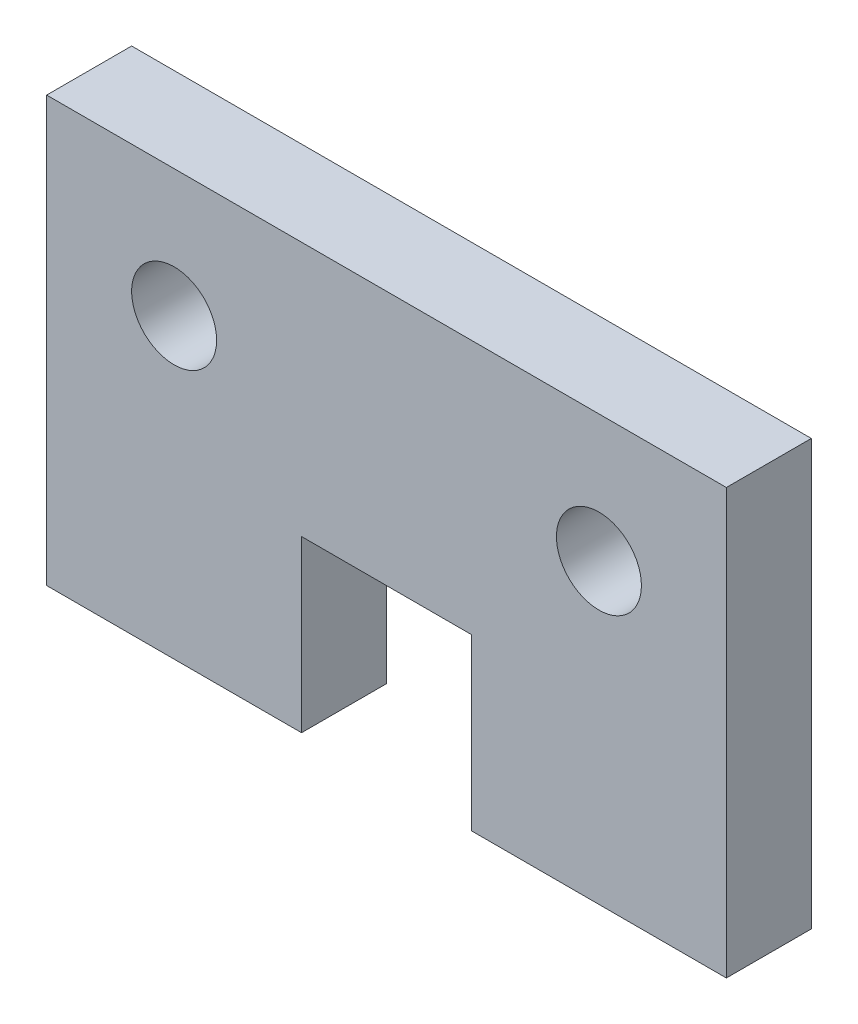
from build123d import *

# Parameters (mm, degrees)
SKETCH1_R           = 6.35
BOSS_EXTRUDE1_DEPTH = 12.7


with BuildPart() as part:
    # Sketch1 → Boss-Extrude1 (new body)
    with BuildSketch(Plane.XY):
        Polygon((-46.25308642, 46.25308642), (-46.25308642, -17.24691358), (-8.15308642, -17.24691358), (-8.15308642, 8.15308642), (17.24691358, 8.15308642), (17.24691358, -17.24691358), (55.34691358, -17.24691358), (55.34691358, 46.25308642), align=None)
        with Locations((-27.20308642, 27.20308642)):
            Circle(SKETCH1_R, mode=Mode.SUBTRACT)
        with Locations((36.29691358, 27.20308642)):
            Circle(SKETCH1_R, mode=Mode.SUBTRACT)
    extrude(amount=BOSS_EXTRUDE1_DEPTH)


solid = part.part
